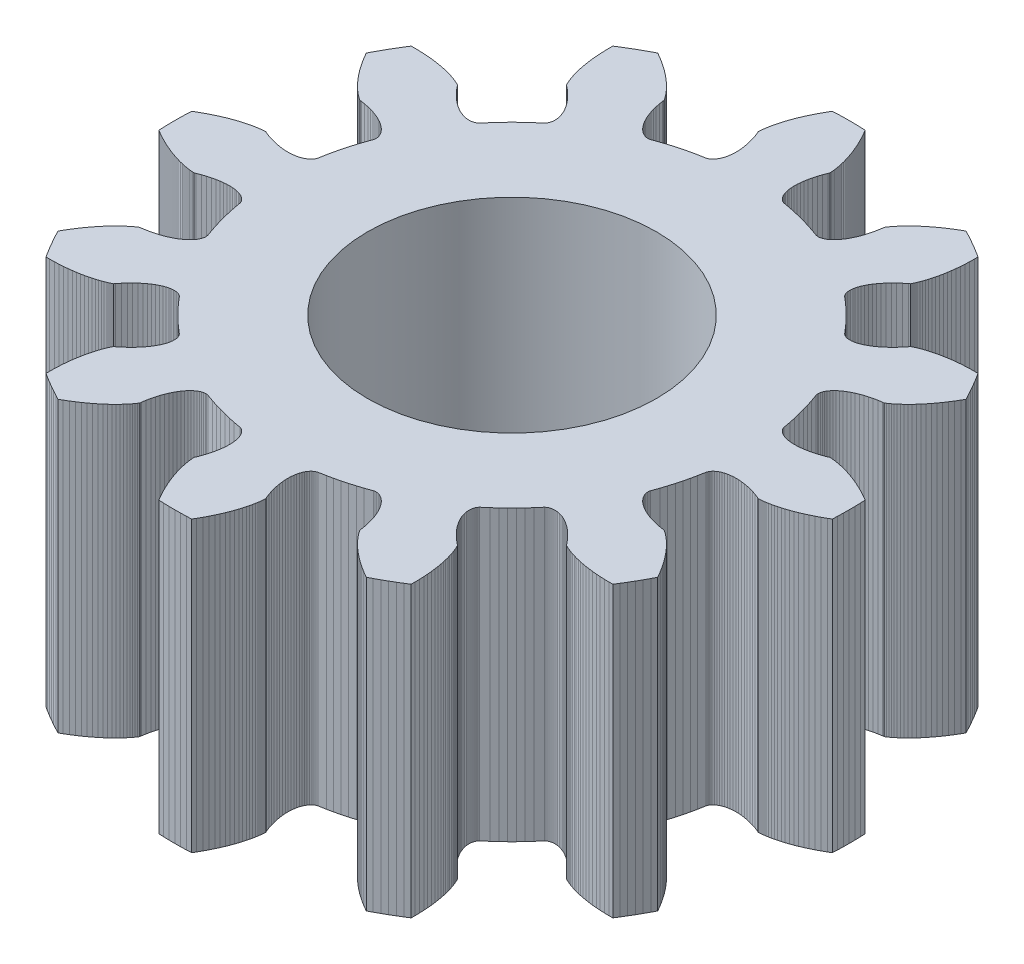
from build123d import *

# Parameters (mm, degrees)
SKETCH3_R           = 3.175
BOSS_EXTRUDE1_DEPTH = 6.35


with BuildPart() as part:
    # Sketch3 → Boss-Extrude1 (new body)
    with BuildSketch(Plane(origin=(0, 0, 0), x_dir=(1, 0, 0), z_dir=(0, 1, 0))):
        Polygon((6.352324032, -3.811995371), (6.415800573, -3.704164188), (6.477446846, -3.5952763), (6.537245267, -3.48536277), (6.588458816, -3.387319635), (6.548537306, -3.316595297), (6.495884299, -3.228769109), (6.443215338, -3.145914469), (6.390753066, -3.06796958), (6.338716813, -2.994864435), (6.287322326, -2.926520952), (6.236781496, -2.862853119), (6.187302087, -2.803767138), (6.139087482, -2.749161584), (6.092336423, -2.698927578), (6.047242762, -2.652948955), (6.003995218, -2.611102449), (5.962777138, -2.573257887), (5.92376627, -2.53927838), (5.887134532, -2.509020536), (5.853047802, -2.482334667), (5.821665703, -2.459065011), (5.793141399, -2.439049957), (5.767621407, -2.422122279), (5.760449484, -2.417630883), (5.727783615, -2.415600485), (5.636581741, -2.400512835), (5.550113125, -2.382418476), (5.468469721, -2.361555299), (5.391734266, -2.338163872), (5.319980198, -2.312487121), (5.253271597, -2.284770003), (5.191663125, -2.255259188), (5.13519999, -2.224202732), (5.083917906, -2.191849747), (5.037843073, -2.158450081), (4.996992084, -2.124254211), (4.961372336, -2.08951179), (4.930981205, -2.054473591), (4.905806921, -2.019388861), (4.885828153, -1.984506202), (4.871014126, -1.950073026), (4.861324716, -1.916335146), (4.856710476, -1.883536522), (4.857112722, -1.851918927), (4.862463612, -1.821721631), (4.91656345, -1.668948402), (4.958566642, -1.539675868), (4.997171481, -1.409348117), (5.032351508, -1.278054469), (5.064082612, -1.145884906), (5.092343047, -1.012930011), (5.121877828, -0.853574595), (5.13234247, -0.824747525), (5.147802912, -0.797164761), (5.168198273, -0.771067439), (5.193458489, -0.746694283), (5.2235044, -0.724281291), (5.258247849, -0.704061425), (5.297591783, -0.686264298), (5.341430376, -0.671115876), (5.389649152, -0.658838167), (5.442125122, -0.649648933), (5.498726931, -0.643761391), (5.559315011, -0.641383926), (5.623741749, -0.642719814), (5.691851657, -0.647966934), (5.76348156, -0.657317507), (5.838460781, -0.670957821), (5.916611348, -0.689067979), (5.997748198, -0.71182164), (6.081679396, -0.739385773), (6.16820636, -0.771920423), (6.197511031, -0.78649498), (6.205967799, -0.786191279), (6.236532595, -0.784291448), (6.271243328, -0.781220033), (6.31005542, -0.776759019), (6.352918329, -0.770691743), (6.399771266, -0.76280355), (6.450545422, -0.752881869), (6.505163607, -0.740716556), (6.563540332, -0.726100191), (6.6255819, -0.708828366), (6.691186508, -0.68869997), (6.760244357, -0.665517476), (6.832637773, -0.639087219), (6.908241333, -0.609219674), (6.986922005, -0.575729725), (7.068539294, -0.538436939), (7.1529454, -0.497165821), (7.239985377, -0.451746078), (7.329497313, -0.402012872), (7.399432523, -0.360724553), (7.404101857, -0.250209934), (7.407271671, -0.125122814), (7.408328376, 0), (7.407271671, 0.125122814), (7.404101857, 0.250209934), (7.399432523, 0.360724553), (7.329497313, 0.402012872), (7.239985377, 0.451746078), (7.1529454, 0.497165821), (7.068539294, 0.538436939), (6.986922005, 0.575729725), (6.908241333, 0.609219674), (6.832637773, 0.639087219), (6.760244357, 0.665517476), (6.691186508, 0.68869997), (6.6255819, 0.708828366), (6.563540332, 0.726100191), (6.505163607, 0.740716556), (6.450545422, 0.752881869), (6.399771266, 0.76280355), (6.352918329, 0.770691743), (6.31005542, 0.776759019), (6.271242896, 0.781220082), (6.236532598, 0.784291476), (6.205967798, 0.786191279), (6.197511031, 0.78649498), (6.16820636, 0.771920423), (6.081679396, 0.739385773), (5.997748198, 0.71182164), (5.916611348, 0.689067979), (5.838460781, 0.670957821), (5.76348156, 0.657317507), (5.691851657, 0.647966934), (5.623741749, 0.642719814), (5.559315011, 0.641383926), (5.498726931, 0.64376139), (5.442125122, 0.649648933), (5.389649193, 0.658837931), (5.341430376, 0.671115876), (5.297591785, 0.686264282), (5.25824785, 0.704061406), (5.2235044, 0.724281291), (5.193458489, 0.746694283), (5.168198273, 0.771067439), (5.147802912, 0.797164761), (5.13234247, 0.824747525), (5.121877828, 0.853574595), (5.092343048, 1.012930011), (5.064082612, 1.145884906), (5.032351508, 1.278054469), (4.997171481, 1.409348117), (4.958566642, 1.539675868), (4.916563449, 1.668948402), (4.862463612, 1.821721631), (4.857112722, 1.851918927), (4.856710476, 1.883536522), (4.861324716, 1.916335146), (4.871014126, 1.950073026), (4.885828153, 1.984506202), (4.905806929, 2.019388845), (4.930981212, 2.054473575), (4.961372336, 2.08951179), (4.996992167, 2.124253986), (5.037843073, 2.158450081), (5.083917906, 2.191849747), (5.13519999, 2.224202732), (5.191663125, 2.255259188), (5.253271597, 2.284770003), (5.319980198, 2.312487121), (5.391734266, 2.338163872), (5.468469721, 2.361555299), (5.550113125, 2.382418476), (5.636581741, 2.400512835), (5.727783615, 2.415600485), (5.760449483, 2.417630883), (5.767621408, 2.42212228), (5.793141383, 2.43904998), (5.821666052, 2.45906527), (5.853047802, 2.482334667), (5.887134532, 2.509020536), (5.92376627, 2.53927838), (5.962777138, 2.573257887), (6.003995218, 2.611102449), (6.047242762, 2.652948955), (6.092336423, 2.698927578), (6.139087482, 2.749161584), (6.187302087, 2.803767138), (6.236781496, 2.862853119), (6.287322326, 2.926520952), (6.338716813, 2.994864435), (6.390753066, 3.06796958), (6.443215338, 3.145914469), (6.495884299, 3.228769109), (6.548537306, 3.316595297), (6.588458816, 3.387319635), (6.537245267, 3.48536277), (6.477446846, 3.5952763), (6.415800573, 3.704164188), (6.352324032, 3.811995371), (6.287035334, 3.918739087), (6.227734262, 4.012112889), (6.146524434, 4.012902016), (6.044138221, 4.011216269), (5.946049518, 4.00703093), (5.852316127, 4.000569714), (5.762987088, 3.99205757), (5.678102653, 3.98172038), (5.597694277, 3.969784654), (5.521784611, 3.95647722), (5.450387512, 3.942024924), (5.383508057, 3.926654322), (5.321142571, 3.910591377), (5.263278662, 3.894061158), (5.20989527, 3.877287535), (5.160962719, 3.860492886), (5.116442789, 3.843897793), (5.076288783, 3.827720753), (5.04044562, 3.812177885), (5.008849923, 3.797482641), (4.981430128, 3.783845519), (4.973954503, 3.779880148), (4.955863193, 3.752605876), (4.897195968, 3.681166561), (4.838291485, 3.615329722), (4.779401742, 3.555056049), (4.720776444, 3.500296909), (4.662662691, 3.450994439), (4.605304663, 3.407081654), (4.548943312, 3.36848256), (4.493816064, 3.335112279), (4.440156515, 3.306877183), (4.38819414, 3.283675041), (4.338154153, 3.265394982), (4.29025646, 3.251918585), (4.244716924, 3.243118194), (4.201745515, 3.238858989), (4.161546862, 3.238998198), (4.124319843, 3.243385462), (4.090257276, 3.251863127), (4.059545715, 3.26426639), (4.032365197, 3.280423543), (4.008889017, 3.300156197), (3.903633438, 3.423394646), (3.812681736, 3.524406745), (3.719117012, 3.623003391), (3.623003391, 3.719117012), (3.524406745, 3.812681736), (3.423394645, 3.903633438), (3.300156197, 4.008889017), (3.280423543, 4.032365197), (3.26426639, 4.059545715), (3.251863127, 4.090257276), (3.243385462, 4.124319843), (3.238998198, 4.161546862), (3.238859004, 4.201745504), (3.243118208, 4.244716913), (3.251918585, 4.29025646), (3.265395166, 4.338153999), (3.283675041, 4.38819414), (3.306877184, 4.440156515), (3.335112279, 4.493816064), (3.36848256, 4.548943312), (3.407081654, 4.605304663), (3.450994439, 4.662662691), (3.500296909, 4.720776444), (3.555056049, 4.779401742), (3.615329722, 4.838291485), (3.681166561, 4.897195968), (3.752605876, 4.955863193), (3.779880148, 4.973954503), (3.783845519, 4.981430129), (3.797482616, 5.008849935), (3.812178058, 5.040446019), (3.827720753, 5.076288783), (3.843897793, 5.116442789), (3.860492886, 5.160962719), (3.877287535, 5.20989527), (3.894061158, 5.263278662), (3.910591377, 5.321142571), (3.926654322, 5.383508057), (3.942024924, 5.450387512), (3.95647722, 5.521784611), (3.969784654, 5.597694277), (3.98172038, 5.678102653), (3.99205757, 5.762987088), (4.000569714, 5.852316127), (4.00703093, 5.946049518), (4.011216269, 6.044138221), (4.012902016, 6.146524434), (4.012112889, 6.227734262), (3.918739087, 6.287035334), (3.811995371, 6.352324032), (3.704164188, 6.415800573), (3.5952763, 6.477446846), (3.48536277, 6.537245267), (3.387319635, 6.588458816), (3.316595297, 6.548537306), (3.228769109, 6.495884299), (3.145914469, 6.443215338), (3.06796958, 6.390753066), (2.994864435, 6.338716813), (2.926520952, 6.287322326), (2.862853119, 6.236781496), (2.803767138, 6.187302087), (2.749161584, 6.139087482), (2.698927578, 6.092336423), (2.652948955, 6.047242762), (2.611102449, 6.003995218), (2.573257887, 5.962777138), (2.53927838, 5.92376627), (2.509020536, 5.887134532), (2.482334667, 5.853047802), (2.459065011, 5.821665703), (2.439049957, 5.793141399), (2.422122279, 5.767621407), (2.417630883, 5.760449484), (2.415600485, 5.727783615), (2.400512835, 5.636581741), (2.382418476, 5.550113125), (2.361555299, 5.468469721), (2.338163872, 5.391734266), (2.312487121, 5.319980198), (2.284770003, 5.253271597), (2.255259188, 5.191663125), (2.224202732, 5.13519999), (2.191849747, 5.083917906), (2.158450081, 5.037843073), (2.124254211, 4.996992084), (2.08951179, 4.961372336), (2.054473591, 4.930981205), (2.019388861, 4.905806921), (1.984506202, 4.885828153), (1.950073026, 4.871014126), (1.916335146, 4.861324716), (1.883536522, 4.856710476), (1.851918927, 4.857112722), (1.821721631, 4.862463612), (1.668948402, 4.91656345), (1.539675868, 4.958566642), (1.409348117, 4.997171481), (1.278054469, 5.032351508), (1.145884906, 5.064082612), (1.012930011, 5.092343047), (0.853574595, 5.121877828), (0.824747525, 5.13234247), (0.797164761, 5.147802912), (0.771067439, 5.168198273), (0.746694283, 5.193458489), (0.724281291, 5.2235044), (0.704061425, 5.258247849), (0.686264298, 5.297591783), (0.671115876, 5.341430376), (0.658838167, 5.389649152), (0.649648933, 5.442125122), (0.643761391, 5.498726931), (0.641383926, 5.559315011), (0.642719814, 5.623741749), (0.647966934, 5.691851657), (0.657317507, 5.76348156), (0.670957821, 5.838460781), (0.689067979, 5.916611348), (0.71182164, 5.997748198), (0.739385773, 6.081679396), (0.771920423, 6.16820636), (0.78649498, 6.197511031), (0.786191279, 6.205967799), (0.784291448, 6.236532595), (0.781220033, 6.271243328), (0.776759019, 6.31005542), (0.770691743, 6.352918329), (0.76280355, 6.399771266), (0.752881869, 6.450545422), (0.740716556, 6.505163607), (0.726100191, 6.563540332), (0.708828366, 6.6255819), (0.68869997, 6.691186508), (0.665517476, 6.760244357), (0.639087219, 6.832637773), (0.609219674, 6.908241333), (0.575729725, 6.986922005), (0.538436939, 7.068539294), (0.497165821, 7.1529454), (0.451746078, 7.239985377), (0.402012872, 7.329497313), (0.360724553, 7.399432523), (0.250209934, 7.404101857), (0.125122814, 7.407271671), (0, 7.408328376), (-0.125122814, 7.407271671), (-0.250209934, 7.404101857), (-0.360724553, 7.399432523), (-0.402012872, 7.329497313), (-0.451746078, 7.239985377), (-0.497165821, 7.1529454), (-0.538436939, 7.068539294), (-0.575729725, 6.986922005), (-0.609219674, 6.908241333), (-0.639087219, 6.832637773), (-0.665517476, 6.760244357), (-0.68869997, 6.691186508), (-0.708828366, 6.6255819), (-0.726100191, 6.563540332), (-0.740716556, 6.505163607), (-0.752881869, 6.450545422), (-0.76280355, 6.399771266), (-0.770691743, 6.352918329), (-0.776759019, 6.31005542), (-0.781220082, 6.271242896), (-0.784291476, 6.236532598), (-0.786191279, 6.205967798), (-0.78649498, 6.197511031), (-0.771920423, 6.16820636), (-0.739385773, 6.081679396), (-0.71182164, 5.997748198), (-0.689067979, 5.916611348), (-0.670957821, 5.838460781), (-0.657317507, 5.76348156), (-0.647966934, 5.691851657), (-0.642719814, 5.623741749), (-0.641383926, 5.559315011), (-0.64376139, 5.498726931), (-0.649648933, 5.442125122), (-0.658837931, 5.389649193), (-0.671115876, 5.341430376), (-0.686264282, 5.297591785), (-0.704061406, 5.25824785), (-0.724281291, 5.2235044), (-0.746694283, 5.193458489), (-0.771067439, 5.168198273), (-0.797164761, 5.147802912), (-0.824747525, 5.13234247), (-0.853574595, 5.121877828), (-1.012930011, 5.092343048), (-1.145884906, 5.064082612), (-1.278054469, 5.032351508), (-1.409348117, 4.997171481), (-1.539675868, 4.958566642), (-1.668948402, 4.916563449), (-1.821721631, 4.862463612), (-1.851918927, 4.857112722), (-1.883536522, 4.856710476), (-1.916335146, 4.861324716), (-1.950073026, 4.871014126), (-1.984506202, 4.885828153), (-2.019388845, 4.905806929), (-2.054473575, 4.930981212), (-2.08951179, 4.961372336), (-2.124253986, 4.996992167), (-2.158450081, 5.037843073), (-2.191849747, 5.083917906), (-2.224202732, 5.13519999), (-2.255259188, 5.191663125), (-2.284770003, 5.253271597), (-2.312487121, 5.319980198), (-2.338163872, 5.391734266), (-2.361555299, 5.468469721), (-2.382418476, 5.550113125), (-2.400512835, 5.636581741), (-2.415600485, 5.727783615), (-2.417630883, 5.760449483), (-2.42212228, 5.767621408), (-2.43904998, 5.793141383), (-2.45906527, 5.821666052), (-2.482334667, 5.853047802), (-2.509020536, 5.887134532), (-2.53927838, 5.92376627), (-2.573257887, 5.962777138), (-2.611102449, 6.003995218), (-2.652948955, 6.047242762), (-2.698927578, 6.092336423), (-2.749161584, 6.139087482), (-2.803767138, 6.187302087), (-2.862853119, 6.236781496), (-2.926520952, 6.287322326), (-2.994864435, 6.338716813), (-3.06796958, 6.390753066), (-3.145914469, 6.443215338), (-3.228769109, 6.495884299), (-3.316595297, 6.548537306), (-3.387319635, 6.588458816), (-3.48536277, 6.537245267), (-3.5952763, 6.477446846), (-3.704164188, 6.415800573), (-3.811995371, 6.352324032), (-3.918739087, 6.287035334), (-4.012112889, 6.227734262), (-4.012902016, 6.146524434), (-4.011216269, 6.044138221), (-4.00703093, 5.946049518), (-4.000569714, 5.852316127), (-3.99205757, 5.762987088), (-3.98172038, 5.678102653), (-3.969784654, 5.597694277), (-3.95647722, 5.521784611), (-3.942024924, 5.450387512), (-3.926654322, 5.383508057), (-3.910591377, 5.321142571), (-3.894061158, 5.263278662), (-3.877287535, 5.20989527), (-3.860492886, 5.160962719), (-3.843897793, 5.116442789), (-3.827720753, 5.076288783), (-3.812177885, 5.04044562), (-3.797482641, 5.008849923), (-3.783845519, 4.981430128), (-3.779880148, 4.973954503), (-3.752605876, 4.955863193), (-3.681166561, 4.897195968), (-3.615329722, 4.838291485), (-3.555056049, 4.779401742), (-3.500296909, 4.720776444), (-3.450994439, 4.662662691), (-3.407081654, 4.605304663), (-3.36848256, 4.548943312), (-3.335112279, 4.493816064), (-3.306877183, 4.440156515), (-3.283675041, 4.38819414), (-3.265394982, 4.338154153), (-3.251918585, 4.29025646), (-3.243118194, 4.244716924), (-3.238858989, 4.201745515), (-3.238998198, 4.161546862), (-3.243385462, 4.124319843), (-3.251863127, 4.090257276), (-3.26426639, 4.059545715), (-3.280423543, 4.032365197), (-3.300156197, 4.008889017), (-3.423394646, 3.903633438), (-3.524406745, 3.812681736), (-3.623003391, 3.719117012), (-3.719117012, 3.623003391), (-3.812681736, 3.524406745), (-3.903633438, 3.423394645), (-4.008889017, 3.300156197), (-4.032365197, 3.280423543), (-4.059545715, 3.26426639), (-4.090257276, 3.251863127), (-4.124319843, 3.243385462), (-4.161546862, 3.238998198), (-4.201745504, 3.238859004), (-4.244716913, 3.243118208), (-4.29025646, 3.251918585), (-4.338153999, 3.265395166), (-4.38819414, 3.283675041), (-4.440156515, 3.306877184), (-4.493816064, 3.335112279), (-4.548943312, 3.36848256), (-4.605304663, 3.407081654), (-4.662662691, 3.450994439), (-4.720776444, 3.500296909), (-4.779401742, 3.555056049), (-4.838291485, 3.615329722), (-4.897195968, 3.681166561), (-4.955863193, 3.752605876), (-4.973954503, 3.779880148), (-4.981430129, 3.783845519), (-5.008849935, 3.797482616), (-5.040446019, 3.812178058), (-5.076288783, 3.827720753), (-5.116442789, 3.843897793), (-5.160962719, 3.860492886), (-5.20989527, 3.877287535), (-5.263278662, 3.894061158), (-5.321142571, 3.910591377), (-5.383508057, 3.926654322), (-5.450387512, 3.942024924), (-5.521784611, 3.95647722), (-5.597694277, 3.969784654), (-5.678102653, 3.98172038), (-5.762987088, 3.99205757), (-5.852316127, 4.000569714), (-5.946049518, 4.00703093), (-6.044138221, 4.011216269), (-6.146524434, 4.012902016), (-6.227734262, 4.012112889), (-6.287035334, 3.918739087), (-6.352324032, 3.811995371), (-6.415800573, 3.704164188), (-6.477446846, 3.5952763), (-6.537245267, 3.48536277), (-6.588458816, 3.387319635), (-6.548537306, 3.316595297), (-6.495884299, 3.228769109), (-6.443215338, 3.145914469), (-6.390753066, 3.06796958), (-6.338716813, 2.994864435), (-6.287322326, 2.926520952), (-6.236781496, 2.862853119), (-6.187302087, 2.803767138), (-6.139087482, 2.749161584), (-6.092336423, 2.698927578), (-6.047242762, 2.652948955), (-6.003995218, 2.611102449), (-5.962777138, 2.573257887), (-5.92376627, 2.53927838), (-5.887134532, 2.509020536), (-5.853047802, 2.482334667), (-5.821665703, 2.459065011), (-5.793141399, 2.439049957), (-5.767621407, 2.422122279), (-5.760449484, 2.417630883), (-5.727783615, 2.415600485), (-5.636581741, 2.400512835), (-5.550113125, 2.382418476), (-5.468469721, 2.361555299), (-5.391734266, 2.338163872), (-5.319980198, 2.312487121), (-5.253271597, 2.284770003), (-5.191663125, 2.255259188), (-5.13519999, 2.224202732), (-5.083917906, 2.191849747), (-5.037843073, 2.158450081), (-4.996992084, 2.124254211), (-4.961372336, 2.08951179), (-4.930981205, 2.054473591), (-4.905806921, 2.019388861), (-4.885828153, 1.984506202), (-4.871014126, 1.950073026), (-4.861324716, 1.916335146), (-4.856710476, 1.883536522), (-4.857112722, 1.851918927), (-4.862463612, 1.821721631), (-4.91656345, 1.668948402), (-4.958566642, 1.539675868), (-4.997171481, 1.409348117), (-5.032351508, 1.278054469), (-5.064082612, 1.145884906), (-5.092343047, 1.012930011), (-5.121877828, 0.853574595), (-5.13234247, 0.824747525), (-5.147802912, 0.797164761), (-5.168198273, 0.771067439), (-5.193458489, 0.746694283), (-5.2235044, 0.724281291), (-5.258247849, 0.704061425), (-5.297591783, 0.686264298), (-5.341430376, 0.671115876), (-5.389649152, 0.658838167), (-5.442125122, 0.649648933), (-5.498726931, 0.643761391), (-5.559315011, 0.641383926), (-5.623741749, 0.642719814), (-5.691851657, 0.647966934), (-5.76348156, 0.657317507), (-5.838460781, 0.670957821), (-5.916611348, 0.689067979), (-5.997748198, 0.71182164), (-6.081679396, 0.739385773), (-6.16820636, 0.771920423), (-6.197511031, 0.78649498), (-6.205967799, 0.786191279), (-6.236532595, 0.784291448), (-6.271243328, 0.781220033), (-6.31005542, 0.776759019), (-6.352918329, 0.770691743), (-6.399771266, 0.76280355), (-6.450545422, 0.752881869), (-6.505163607, 0.740716556), (-6.563540332, 0.726100191), (-6.6255819, 0.708828366), (-6.691186508, 0.68869997), (-6.760244357, 0.665517476), (-6.832637773, 0.639087219), (-6.908241333, 0.609219674), (-6.986922005, 0.575729725), (-7.068539294, 0.538436939), (-7.1529454, 0.497165821), (-7.239985377, 0.451746078), (-7.329497313, 0.402012872), (-7.399432523, 0.360724553), (-7.404101857, 0.250209934), (-7.407271671, 0.125122814), (-7.408328376, 0), (-7.407271671, -0.125122814), (-7.404101857, -0.250209934), (-7.399432523, -0.360724553), (-7.329497313, -0.402012872), (-7.239985377, -0.451746078), (-7.1529454, -0.497165821), (-7.068539294, -0.538436939), (-6.986922005, -0.575729725), (-6.908241333, -0.609219674), (-6.832637773, -0.639087219), (-6.760244357, -0.665517476), (-6.691186508, -0.68869997), (-6.6255819, -0.708828366), (-6.563540332, -0.726100191), (-6.505163607, -0.740716556), (-6.450545422, -0.752881869), (-6.399771266, -0.76280355), (-6.352918329, -0.770691743), (-6.31005542, -0.776759019), (-6.271242896, -0.781220082), (-6.236532598, -0.784291476), (-6.205967798, -0.786191279), (-6.197511031, -0.78649498), (-6.16820636, -0.771920423), (-6.081679396, -0.739385773), (-5.997748198, -0.71182164), (-5.916611348, -0.689067979), (-5.838460781, -0.670957821), (-5.76348156, -0.657317507), (-5.691851657, -0.647966934), (-5.623741749, -0.642719814), (-5.559315011, -0.641383926), (-5.498726931, -0.64376139), (-5.442125122, -0.649648933), (-5.389649193, -0.658837931), (-5.341430376, -0.671115876), (-5.297591785, -0.686264282), (-5.25824785, -0.704061406), (-5.2235044, -0.724281291), (-5.193458489, -0.746694283), (-5.168198273, -0.771067439), (-5.147802912, -0.797164761), (-5.13234247, -0.824747525), (-5.121877828, -0.853574595), (-5.092343048, -1.012930011), (-5.064082612, -1.145884906), (-5.032351508, -1.278054469), (-4.997171481, -1.409348117), (-4.958566642, -1.539675868), (-4.916563449, -1.668948402), (-4.862463612, -1.821721631), (-4.857112722, -1.851918927), (-4.856710476, -1.883536522), (-4.861324716, -1.916335146), (-4.871014126, -1.950073026), (-4.885828153, -1.984506202), (-4.905806929, -2.019388845), (-4.930981212, -2.054473575), (-4.961372336, -2.08951179), (-4.996992167, -2.124253986), (-5.037843073, -2.158450081), (-5.083917906, -2.191849747), (-5.13519999, -2.224202732), (-5.191663125, -2.255259188), (-5.253271597, -2.284770003), (-5.319980198, -2.312487121), (-5.391734266, -2.338163872), (-5.468469721, -2.361555299), (-5.550113125, -2.382418476), (-5.636581741, -2.400512835), (-5.727783615, -2.415600485), (-5.760449483, -2.417630883), (-5.767621408, -2.42212228), (-5.793141383, -2.43904998), (-5.821666052, -2.45906527), (-5.853047802, -2.482334667), (-5.887134532, -2.509020536), (-5.92376627, -2.53927838), (-5.962777138, -2.573257887), (-6.003995218, -2.611102449), (-6.047242762, -2.652948955), (-6.092336423, -2.698927578), (-6.139087482, -2.749161584), (-6.187302087, -2.803767138), (-6.236781496, -2.862853119), (-6.287322326, -2.926520952), (-6.338716813, -2.994864435), (-6.390753066, -3.06796958), (-6.443215338, -3.145914469), (-6.495884299, -3.228769109), (-6.548537306, -3.316595297), (-6.588458816, -3.387319635), (-6.537245267, -3.48536277), (-6.477446846, -3.5952763), (-6.415800573, -3.704164188), (-6.352324032, -3.811995371), (-6.287035334, -3.918739087), (-6.227734262, -4.012112889), (-6.146524434, -4.012902016), (-6.044138221, -4.011216269), (-5.946049518, -4.00703093), (-5.852316127, -4.000569714), (-5.762987088, -3.99205757), (-5.678102653, -3.98172038), (-5.597694277, -3.969784654), (-5.521784611, -3.95647722), (-5.450387512, -3.942024924), (-5.383508057, -3.926654322), (-5.321142571, -3.910591377), (-5.263278662, -3.894061158), (-5.20989527, -3.877287535), (-5.160962719, -3.860492886), (-5.116442789, -3.843897793), (-5.076288783, -3.827720753), (-5.04044562, -3.812177885), (-5.008849923, -3.797482641), (-4.981430128, -3.783845519), (-4.973954503, -3.779880148), (-4.955863193, -3.752605876), (-4.897195968, -3.681166561), (-4.838291485, -3.615329722), (-4.779401742, -3.555056049), (-4.720776444, -3.500296909), (-4.662662691, -3.450994439), (-4.605304663, -3.407081654), (-4.548943312, -3.36848256), (-4.493816064, -3.335112279), (-4.440156515, -3.306877183), (-4.38819414, -3.283675041), (-4.338154153, -3.265394982), (-4.29025646, -3.251918585), (-4.244716924, -3.243118194), (-4.201745515, -3.238858989), (-4.161546862, -3.238998198), (-4.124319843, -3.243385462), (-4.090257276, -3.251863127), (-4.059545715, -3.26426639), (-4.032365197, -3.280423543), (-4.008889017, -3.300156197), (-3.903633438, -3.423394646), (-3.812681736, -3.524406745), (-3.719117012, -3.623003391), (-3.623003391, -3.719117012), (-3.524406745, -3.812681736), (-3.423394645, -3.903633438), (-3.300156197, -4.008889017), (-3.280423543, -4.032365197), (-3.26426639, -4.059545715), (-3.251863127, -4.090257276), (-3.243385462, -4.124319843), (-3.238998198, -4.161546862), (-3.238859004, -4.201745504), (-3.243118208, -4.244716913), (-3.251918585, -4.29025646), (-3.265395166, -4.338153999), (-3.283675041, -4.38819414), (-3.306877184, -4.440156515), (-3.335112279, -4.493816064), (-3.36848256, -4.548943312), (-3.407081654, -4.605304663), (-3.450994439, -4.662662691), (-3.500296909, -4.720776444), (-3.555056049, -4.779401742), (-3.615329722, -4.838291485), (-3.681166561, -4.897195968), (-3.752605876, -4.955863193), (-3.779880148, -4.973954503), (-3.783845519, -4.981430129), (-3.797482616, -5.008849935), (-3.812178058, -5.040446019), (-3.827720753, -5.076288783), (-3.843897793, -5.116442789), (-3.860492886, -5.160962719), (-3.877287535, -5.20989527), (-3.894061158, -5.263278662), (-3.910591377, -5.321142571), (-3.926654322, -5.383508057), (-3.942024924, -5.450387512), (-3.95647722, -5.521784611), (-3.969784654, -5.597694277), (-3.98172038, -5.678102653), (-3.99205757, -5.762987088), (-4.000569714, -5.852316127), (-4.00703093, -5.946049518), (-4.011216269, -6.044138221), (-4.012902016, -6.146524434), (-4.012112889, -6.227734262), (-3.918739087, -6.287035334), (-3.811995371, -6.352324032), (-3.704164188, -6.415800573), (-3.5952763, -6.477446846), (-3.48536277, -6.537245267), (-3.387319635, -6.588458816), (-3.316595297, -6.548537306), (-3.228769109, -6.495884299), (-3.145914469, -6.443215338), (-3.06796958, -6.390753066), (-2.994864435, -6.338716813), (-2.926520952, -6.287322326), (-2.862853119, -6.236781496), (-2.803767138, -6.187302087), (-2.749161584, -6.139087482), (-2.698927578, -6.092336423), (-2.652948955, -6.047242762), (-2.611102449, -6.003995218), (-2.573257887, -5.962777138), (-2.53927838, -5.92376627), (-2.509020536, -5.887134532), (-2.482334667, -5.853047802), (-2.459065011, -5.821665703), (-2.439049957, -5.793141399), (-2.422122279, -5.767621407), (-2.417630883, -5.760449484), (-2.415600485, -5.727783615), (-2.400512835, -5.636581741), (-2.382418476, -5.550113125), (-2.361555299, -5.468469721), (-2.338163872, -5.391734266), (-2.312487121, -5.319980198), (-2.284770003, -5.253271597), (-2.255259188, -5.191663125), (-2.224202732, -5.13519999), (-2.191849747, -5.083917906), (-2.158450081, -5.037843073), (-2.124254211, -4.996992084), (-2.08951179, -4.961372336), (-2.054473591, -4.930981205), (-2.019388861, -4.905806921), (-1.984506202, -4.885828153), (-1.950073026, -4.871014126), (-1.916335146, -4.861324716), (-1.883536522, -4.856710476), (-1.851918927, -4.857112722), (-1.821721631, -4.862463612), (-1.668948402, -4.91656345), (-1.539675868, -4.958566642), (-1.409348117, -4.997171481), (-1.278054469, -5.032351508), (-1.145884906, -5.064082612), (-1.012930011, -5.092343047), (-0.853574595, -5.121877828), (-0.824747525, -5.13234247), (-0.797164761, -5.147802912), (-0.771067439, -5.168198273), (-0.746694283, -5.193458489), (-0.724281291, -5.2235044), (-0.704061425, -5.258247849), (-0.686264298, -5.297591783), (-0.671115876, -5.341430376), (-0.658838167, -5.389649152), (-0.649648933, -5.442125122), (-0.643761391, -5.498726931), (-0.641383926, -5.559315011), (-0.642719814, -5.623741749), (-0.647966934, -5.691851657), (-0.657317507, -5.76348156), (-0.670957821, -5.838460781), (-0.689067979, -5.916611348), (-0.71182164, -5.997748198), (-0.739385773, -6.081679396), (-0.771920423, -6.16820636), (-0.78649498, -6.197511031), (-0.786191279, -6.205967799), (-0.784291448, -6.236532595), (-0.781220033, -6.271243328), (-0.776759019, -6.31005542), (-0.770691743, -6.352918329), (-0.76280355, -6.399771266), (-0.752881869, -6.450545422), (-0.740716556, -6.505163607), (-0.726100191, -6.563540332), (-0.708828366, -6.6255819), (-0.68869997, -6.691186508), (-0.665517476, -6.760244357), (-0.639087219, -6.832637773), (-0.609219674, -6.908241333), (-0.575729725, -6.986922005), (-0.538436939, -7.068539294), (-0.497165821, -7.1529454), (-0.451746078, -7.239985377), (-0.402012872, -7.329497313), (-0.360724553, -7.399432523), (-0.250209934, -7.404101857), (-0.125122814, -7.407271671), (0, -7.408328376), (0.125122814, -7.407271671), (0.250209934, -7.404101857), (0.360724553, -7.399432523), (0.402012872, -7.329497313), (0.451746078, -7.239985377), (0.497165821, -7.1529454), (0.538436939, -7.068539294), (0.575729725, -6.986922005), (0.609219674, -6.908241333), (0.639087219, -6.832637773), (0.665517476, -6.760244357), (0.68869997, -6.691186508), (0.708828366, -6.6255819), (0.726100191, -6.563540332), (0.740716556, -6.505163607), (0.752881869, -6.450545422), (0.76280355, -6.399771266), (0.770691743, -6.352918329), (0.776759019, -6.31005542), (0.781220082, -6.271242896), (0.784291476, -6.236532598), (0.786191279, -6.205967798), (0.78649498, -6.197511031), (0.771920423, -6.16820636), (0.739385773, -6.081679396), (0.71182164, -5.997748198), (0.689067979, -5.916611348), (0.670957821, -5.838460781), (0.657317507, -5.76348156), (0.647966934, -5.691851657), (0.642719814, -5.623741749), (0.641383926, -5.559315011), (0.64376139, -5.498726931), (0.649648933, -5.442125122), (0.658837931, -5.389649193), (0.671115876, -5.341430376), (0.686264282, -5.297591785), (0.704061406, -5.25824785), (0.724281291, -5.2235044), (0.746694283, -5.193458489), (0.771067439, -5.168198273), (0.797164761, -5.147802912), (0.824747525, -5.13234247), (0.853574595, -5.121877828), (1.012930011, -5.092343048), (1.145884906, -5.064082612), (1.278054469, -5.032351508), (1.409348117, -4.997171481), (1.539675868, -4.958566642), (1.668948402, -4.916563449), (1.821721631, -4.862463612), (1.851918927, -4.857112722), (1.883536522, -4.856710476), (1.916335146, -4.861324716), (1.950073026, -4.871014126), (1.984506202, -4.885828153), (2.019388845, -4.905806929), (2.054473575, -4.930981212), (2.08951179, -4.961372336), (2.124253986, -4.996992167), (2.158450081, -5.037843073), (2.191849747, -5.083917906), (2.224202732, -5.13519999), (2.255259188, -5.191663125), (2.284770003, -5.253271597), (2.312487121, -5.319980198), (2.338163872, -5.391734266), (2.361555299, -5.468469721), (2.382418476, -5.550113125), (2.400512835, -5.636581741), (2.415600485, -5.727783615), (2.417630883, -5.760449483), (2.42212228, -5.767621408), (2.43904998, -5.793141383), (2.45906527, -5.821666052), (2.482334667, -5.853047802), (2.509020536, -5.887134532), (2.53927838, -5.92376627), (2.573257887, -5.962777138), (2.611102449, -6.003995218), (2.652948955, -6.047242762), (2.698927578, -6.092336423), (2.749161584, -6.139087482), (2.803767138, -6.187302087), (2.862853119, -6.236781496), (2.926520952, -6.287322326), (2.994864435, -6.338716813), (3.06796958, -6.390753066), (3.145914469, -6.443215338), (3.228769109, -6.495884299), (3.316595297, -6.548537306), (3.387319635, -6.588458816), (3.48536277, -6.537245267), (3.5952763, -6.477446846), (3.704164188, -6.415800573), (3.811995371, -6.352324032), (3.918739087, -6.287035334), (4.012112889, -6.227734262), (4.012902016, -6.146524434), (4.011216269, -6.044138221), (4.00703093, -5.946049518), (4.000569714, -5.852316127), (3.99205757, -5.762987088), (3.98172038, -5.678102653), (3.969784654, -5.597694277), (3.95647722, -5.521784611), (3.942024924, -5.450387512), (3.926654322, -5.383508057), (3.910591377, -5.321142571), (3.894061158, -5.263278662), (3.877287535, -5.20989527), (3.860492886, -5.160962719), (3.843897793, -5.116442789), (3.827720753, -5.076288783), (3.812177885, -5.04044562), (3.797482641, -5.008849923), (3.783845519, -4.981430128), (3.779880148, -4.973954503), (3.752605876, -4.955863193), (3.681166561, -4.897195968), (3.615329722, -4.838291485), (3.555056049, -4.779401742), (3.500296909, -4.720776444), (3.450994439, -4.662662691), (3.407081654, -4.605304663), (3.36848256, -4.548943312), (3.335112279, -4.493816064), (3.306877183, -4.440156515), (3.283675041, -4.38819414), (3.265394982, -4.338154153), (3.251918585, -4.29025646), (3.243118194, -4.244716924), (3.238858989, -4.201745515), (3.238998198, -4.161546862), (3.243385462, -4.124319843), (3.251863127, -4.090257276), (3.26426639, -4.059545715), (3.280423543, -4.032365197), (3.300156197, -4.008889017), (3.423394646, -3.903633438), (3.524406745, -3.812681736), (3.623003391, -3.719117012), (3.719117012, -3.623003391), (3.812681736, -3.524406745), (3.903633438, -3.423394645), (4.008889017, -3.300156197), (4.032365197, -3.280423543), (4.059545715, -3.26426639), (4.090257276, -3.251863127), (4.124319843, -3.243385462), (4.161546862, -3.238998198), (4.201745504, -3.238859004), (4.244716913, -3.243118208), (4.29025646, -3.251918585), (4.338153999, -3.265395166), (4.38819414, -3.283675041), (4.440156515, -3.306877184), (4.493816064, -3.335112279), (4.548943312, -3.36848256), (4.605304663, -3.407081654), (4.662662691, -3.450994439), (4.720776444, -3.500296909), (4.779401742, -3.555056049), (4.838291485, -3.615329722), (4.897195968, -3.681166561), (4.955863193, -3.752605876), (4.973954503, -3.779880148), (4.981430129, -3.783845519), (5.008849935, -3.797482616), (5.040446019, -3.812178058), (5.076288783, -3.827720753), (5.116442789, -3.843897793), (5.160962719, -3.860492886), (5.20989527, -3.877287535), (5.263278662, -3.894061158), (5.321142571, -3.910591377), (5.383508057, -3.926654322), (5.450387512, -3.942024924), (5.521784611, -3.95647722), (5.597694277, -3.969784654), (5.678102653, -3.98172038), (5.762987088, -3.99205757), (5.852316127, -4.000569714), (5.946049518, -4.00703093), (6.044138221, -4.011216269), (6.146524434, -4.012902016), (6.227734262, -4.012112889), (6.287035334, -3.918739087), align=None)
        Circle(SKETCH3_R, mode=Mode.SUBTRACT)
    extrude(amount=BOSS_EXTRUDE1_DEPTH)


solid = part.part
